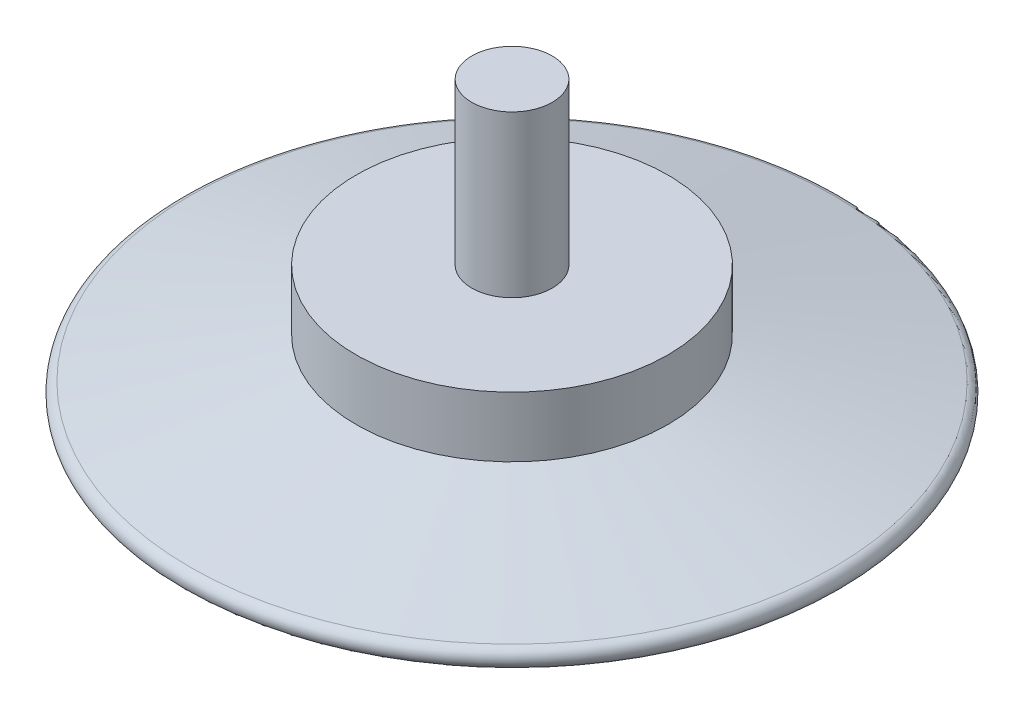
from build123d import *


with BuildPart() as part:
    # 草图1 → 旋转1 (revolve)
    with BuildSketch(Plane.XY):
        with BuildLine():
            Line((0, 14), (-2, 14))
            Line((-2, 14), (-2, 6))
            Line((-2, 6), (-7.75, 6))
            Line((-7.75, 6), (-7.75, 3))
            Line((-7.75, 3), (-16, 0.985732061))
            ThreePointArc((-16, 0.985732061), (-16.377826925, 0.440275761), (-15.881406725, 0))
            Line((-15.881406725, 0), (0, 0))
            Line((0, 0), (0, 14))
        make_face()
    revolve(axis=Axis((0, 0, 0), (0, 1, 0)))


solid = part.part
